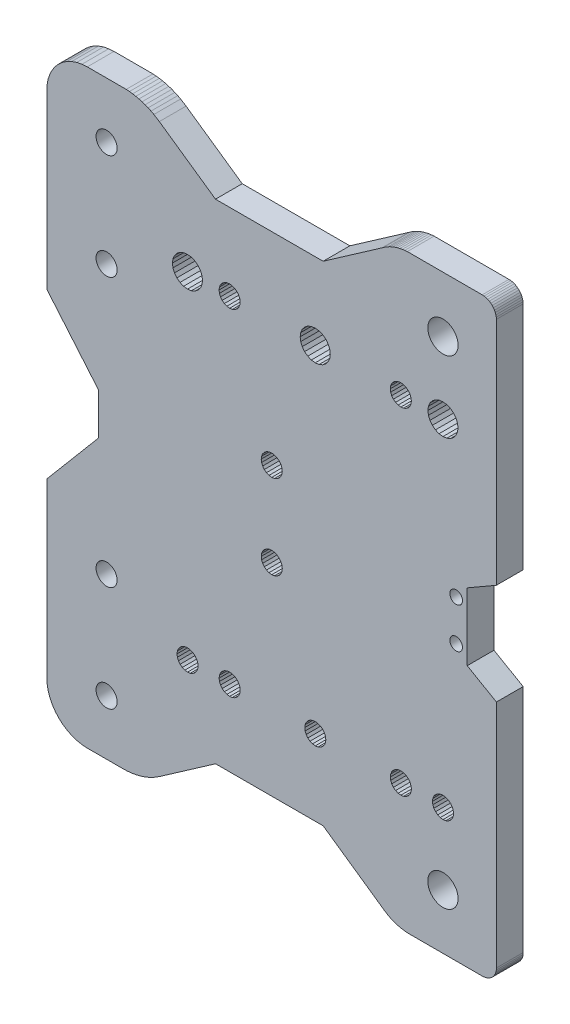
from build123d import *

# Parameters (mm, degrees)
MODEL_R             = 2.5
MODEL_R_2           = 1.5
MODEL_R_3           = 2.500000001
MODEL_R_4           = 3.6
BOSS_EXTRUDE1_DEPTH = 6.35


with BuildPart() as part:
    # Model → Boss-Extrude1 (new body)
    with BuildSketch(Plane.XY):
        Polygon((606.504363005, 163.455463636), (606.50782997, 147.455463886), (613.4360332, 143.455463886), (613.44392881, 88.798247656), (613.415223141, 88.359312218), (613.329470481, 87.927878776), (613.188138083, 87.511329275), (612.993644182, 87.116790992), (612.749316625, 86.751014587), (612.459335922, 86.420258596), (612.128663724, 86.130182345), (611.762957924, 85.88574912), (611.368475849, 85.69114124), (610.951967198, 85.549688501), (610.520558549, 85.463811197), (610.081631423, 85.434978715), (592.905761978, 85.439303293), (592.309445462, 85.455624065), (591.714939398, 85.504840872), (591.12405712, 85.586803594), (590.53860091, 85.701262234), (589.960356498, 85.847867673), (589.391087619, 86.026172744), (588.832530631, 86.235633588), (588.286389218, 86.475611319), (587.754329194, 86.745373966), (586.738896875, 87.370874402), (586.258621804, 87.72470432), (572.318335171, 97.436568259), (546.77102369, 97.424556188), (533.438032454, 88.130387183), (532.140915056, 87.320684471), (531.463244887, 86.966181731), (530.768474551, 86.646489331), (530.058390747, 86.362429405), (529.334819555, 86.114732453), (528.599621739, 85.904035462), (527.854687964, 85.730880268), (527.10193393, 85.595712166), (526.343295452, 85.498878757), (525.580723472, 85.440629064), (524.816179053, 85.421112883), (516.336465852, 85.419733916), (515.082354318, 85.501750787), (513.849677231, 85.746760396), (512.659526039, 86.15057056), (511.532264559, 86.706271975), (510.487180546, 87.404356436), (509.542155679, 88.232879525), (508.713359594, 89.177664981), (508.014973223, 90.222547264), (507.45894615, 91.349648147), (507.054792152, 92.539682623), (506.809426416, 93.772288872), (506.727047218, 95.026376658), (506.721133668, 135.962816223), (518.936441958, 150.441812844), (518.934997389, 160.44181274), (506.715502507, 174.944426011), (506.709593124, 215.852016485), (506.791609995, 217.10612802), (507.036619604, 218.338805107), (507.440429768, 219.528956299), (507.996131183, 220.656217779), (508.694215644, 221.701301792), (509.522738733, 222.646326659), (510.467524189, 223.475122744), (511.512406472, 224.173509115), (512.639507356, 224.729536188), (513.829541832, 225.133690186), (515.06214808, 225.379055922), (516.316235866, 225.46143512), (525.560496495, 225.461500347), (526.323085272, 225.403470973), (527.081751696, 225.30685675), (527.834544749, 225.171906134), (528.57952852, 224.99896617), (529.314787179, 224.788481596), (530.038429904, 224.540993704), (530.748595747, 224.257138942), (531.443458418, 223.937647284), (532.121230979, 223.583340347), (533.418582258, 222.774012425), (546.75425815, 213.483695891), (572.301569754, 213.494856629), (586.239049914, 223.210747703), (586.719222739, 223.564716363), (587.7344743, 224.190510146), (588.266456363, 224.460426501), (588.812528421, 224.700562009), (589.37102487, 224.91018422), (589.94024221, 225.088653753), (590.518444241, 225.235426249), (591.103867358, 225.35005403), (591.694725932, 225.432187463), (592.289217752, 225.481576028), (610.061401683, 225.474977253), (610.500337121, 225.446271584), (610.931770563, 225.360518924), (611.348320065, 225.219186525), (611.742858347, 225.024692625), (612.108634752, 224.780365067), (612.439390743, 224.490384364), (612.729466994, 224.159712166), (612.97390022, 223.794006366), (613.168508099, 223.399524292), (613.309960839, 222.983015641), (613.395838142, 222.551606992), (613.424670625, 222.112679866), (613.432566235, 167.455463636), align=None)
        with Locations((520.901831188, 187.242801268)):
            Circle(MODEL_R, mode=Mode.SUBTRACT)
        with Locations((603.881271716, 150.664358716)):
            Circle(MODEL_R_2, mode=Mode.SUBTRACT)
        with Locations((603.881271716, 160.244358616)):
            Circle(MODEL_R_2, mode=Mode.SUBTRACT)
        with Locations((520.902281683, 123.476551269)):
            Circle(MODEL_R_3, mode=Mode.SUBTRACT)
        with Locations((600.742457856, 98.47958)):
            Circle(MODEL_R_4, mode=Mode.SUBTRACT)
        with Locations((600.745309717, 212.245836)):
            Circle(MODEL_R_4, mode=Mode.SUBTRACT)
        with Locations((520.905302241, 212.245836805)):
            Circle(MODEL_R, mode=Mode.SUBTRACT)
        with Locations((520.906104967, 98.479586806)):
            Circle(MODEL_R, mode=Mode.SUBTRACT)
        Polygon((547.938669143, 193.99416413), (548.336040491, 193.476454574), (548.853864831, 193.079232817), (549.456853291, 192.829568864), (550.103913203, 192.744476901), (550.750948503, 192.829755805), (551.353864806, 193.079593959), (551.871574362, 193.476965306), (552.268796119, 193.994789647), (552.518460073, 194.597778106), (552.603552036, 195.244838018), (552.518273132, 195.891873319), (552.268434977, 196.494789622), (551.87106363, 197.012499177), (551.35323929, 197.409720935), (550.75025083, 197.659384888), (550.103190918, 197.744476851), (549.456155618, 197.659197947), (548.853239315, 197.409359793), (548.335529759, 197.011988445), (547.938308001, 196.494164105), (547.688644048, 195.891175646), (547.603552085, 195.244115734), (547.688830989, 194.597080433), align=None, mode=Mode.SUBTRACT)
        Polygon((557.945858514, 144.226600638), (558.343229862, 143.708891083), (558.861054202, 143.311669325), (559.464042661, 143.062005372), (560.111102573, 142.976913409), (560.758137874, 143.062192313), (561.361054177, 143.312030467), (561.878763733, 143.709401815), (562.27598549, 144.227226155), (562.525649443, 144.830214614), (562.610741406, 145.477274526), (562.525462502, 146.124309827), (562.275624348, 146.72722613), (561.878253, 147.244935686), (561.36042866, 147.642157443), (560.757440201, 147.891821397), (560.110380289, 147.976913359), (559.463344988, 147.891634455), (558.860428685, 147.641796301), (558.34271913, 147.244424954), (557.945497372, 146.726600614), (557.695833419, 146.123612154), (557.610741456, 145.476552242), (557.69602036, 144.829516941), align=None, mode=Mode.SUBTRACT)
        Polygon((598.59019624, 114.20099651), (598.987567588, 113.683286955), (599.505391927, 113.286065197), (600.108380387, 113.036401244), (600.755440299, 112.951309281), (601.4024756, 113.036588185), (602.005391903, 113.286426339), (602.523101458, 113.683797687), (602.920323216, 114.201622027), (603.169987169, 114.804610486), (603.255079132, 115.451670398), (603.169800228, 116.098705699), (602.919962074, 116.701622002), (602.522590726, 117.219331557), (602.004766386, 117.616553315), (601.401777927, 117.866217268), (600.754718015, 117.951309231), (600.107682714, 117.866030327), (599.504766411, 117.616192173), (598.987056855, 117.218820825), (598.589835098, 116.700996485), (598.340171145, 116.098008026), (598.255079182, 115.450948114), (598.340358086, 114.803912813), align=None, mode=Mode.SUBTRACT)
        Polygon((597.65288206, 197.035595722), (597.296511733, 196.174889995), (597.175051466, 195.251276677), (597.296778573, 194.327698489), (597.653397554, 193.467095759), (598.220605416, 192.728117139), (598.959747878, 192.161122803), (599.820453605, 191.804752476), (600.744066923, 191.683292208), (601.667645111, 191.805019316), (602.528247842, 192.161638297), (603.267226461, 192.728846159), (603.834220798, 193.467988621), (604.190591124, 194.328694348), (604.312051392, 195.252307666), (604.190324285, 196.175885854), (603.833705303, 197.036488584), (603.266497442, 197.775467204), (602.527354979, 198.34246154), (601.666649252, 198.698831867), (600.743035934, 198.820292135), (599.819457747, 198.698565027), (598.958855016, 198.341946046), (598.219876397, 197.774738185), align=None, mode=Mode.SUBTRACT)
        Polygon((537.950196976, 114.192236646), (538.347568323, 113.67452709), (538.865392663, 113.277305333), (539.468381123, 113.027641379), (540.115441035, 112.942549416), (540.762476336, 113.02782832), (541.365392639, 113.277666475), (541.883102194, 113.675037822), (542.280323952, 114.192862162), (542.529987905, 114.795850622), (542.615079868, 115.442910534), (542.529800964, 116.089945834), (542.27996281, 116.692862137), (541.882591462, 117.210571693), (541.364767122, 117.607793451), (540.761778662, 117.857457404), (540.11471875, 117.942549367), (539.46768345, 117.857270463), (538.864767147, 117.607432308), (538.347057591, 117.210060961), (537.949835834, 116.692236621), (537.70017188, 116.089248161), (537.615079917, 115.442188249), (537.700358821, 114.795152949), align=None, mode=Mode.SUBTRACT)
        Polygon((547.95019499, 114.206702671), (548.347566338, 113.688993115), (548.865390678, 113.291771357), (549.468379138, 113.042107404), (550.115439049, 112.957015441), (550.76247435, 113.042294345), (551.365390653, 113.2921325), (551.883100209, 113.689503847), (552.280321966, 114.207328187), (552.529985919, 114.810316647), (552.615077883, 115.457376559), (552.529798979, 116.104411859), (552.279960824, 116.707328162), (551.882589477, 117.225037718), (551.364765137, 117.622259476), (550.761776677, 117.871923429), (550.114716765, 117.957015392), (549.467681464, 117.871736488), (548.864765161, 117.621898333), (548.347055606, 117.224526986), (547.949833848, 116.706702646), (547.700169895, 116.103714186), (547.615077932, 115.456654274), (547.700356836, 114.809618974), align=None, mode=Mode.SUBTRACT)
        Polygon((567.337421335, 197.031216445), (566.981051009, 196.170510719), (566.859590741, 195.246897401), (566.981317848, 194.323319213), (567.337936829, 193.462716482), (567.905144691, 192.723737863), (568.644287154, 192.156743526), (569.50499288, 191.8003732), (570.428606198, 191.678912932), (571.352184386, 191.800640039), (572.212787117, 192.157259021), (572.951765736, 192.724466882), (573.518760073, 193.463609345), (573.875130399, 194.324315071), (573.996590667, 195.247928389), (573.87486356, 196.171506577), (573.518244578, 197.032109308), (572.951036717, 197.771087927), (572.211894254, 198.338082264), (571.351188527, 198.69445259), (570.427575209, 198.815912858), (569.503997022, 198.694185751), (568.643394291, 198.337566769), (567.904415672, 197.770358908), align=None, mode=Mode.SUBTRACT)
        Polygon((568.274735515, 114.196617234), (568.672106862, 113.678907678), (569.189931203, 113.28168592), (569.792919662, 113.032021967), (570.439979574, 112.946930004), (571.087014875, 113.032208908), (571.689931178, 113.282047063), (572.207640733, 113.67941841), (572.604862491, 114.19724275), (572.854526444, 114.80023121), (572.939618407, 115.447291122), (572.854339503, 116.094326422), (572.604501349, 116.697242725), (572.207130001, 117.214952281), (571.689305661, 117.612174039), (571.086317202, 117.861837992), (570.43925729, 117.946929955), (569.792221989, 117.861651051), (569.189305686, 117.611812896), (568.67159613, 117.214441549), (568.274374373, 116.696617209), (568.02471042, 116.093628749), (567.939618457, 115.446568837), (568.024897361, 114.799533537), align=None, mode=Mode.SUBTRACT)
        Polygon((588.590194463, 114.212573398), (588.987565811, 113.694863842), (589.505390151, 113.297642085), (590.10837861, 113.047978131), (590.755438522, 112.962886169), (591.402473823, 113.048165072), (592.005390126, 113.298003227), (592.523099682, 113.695374574), (592.920321439, 114.213198914), (593.169985392, 114.816187374), (593.255077355, 115.463247286), (593.169798451, 116.110282587), (592.919960297, 116.71319889), (592.522588949, 117.230908445), (592.004764609, 117.628130203), (591.40177615, 117.877794156), (590.754716238, 117.962886119), (590.107680937, 117.877607215), (589.504764634, 117.627769061), (588.987055079, 117.230397713), (588.589833321, 116.712573373), (588.340169368, 116.109584913), (588.255077405, 115.462525002), (588.340356309, 114.815489701), align=None, mode=Mode.SUBTRACT)
        Polygon((588.578668616, 194.000034857), (588.976039964, 193.482325301), (589.493864304, 193.085103544), (590.096852763, 192.835439591), (590.743912675, 192.750347628), (591.390947976, 192.835626532), (591.993864279, 193.085464686), (592.511573835, 193.482836034), (592.908795592, 194.000660374), (593.158459545, 194.603648833), (593.243551508, 195.250708745), (593.158272604, 195.897744046), (592.90843445, 196.500660349), (592.511063102, 197.018369904), (591.993238762, 197.415591662), (591.390250303, 197.665255615), (590.743190391, 197.750347578), (590.09615509, 197.665068674), (589.493238787, 197.41523052), (588.975529232, 197.017859172), (588.578307474, 196.500034832), (588.328643521, 195.897046373), (588.243551558, 195.249986461), (588.328830462, 194.60295116), align=None, mode=Mode.SUBTRACT)
        Polygon((557.942969377, 164.22660043), (558.340340724, 163.708890874), (558.858165064, 163.311669117), (559.461153524, 163.062005163), (560.108213436, 162.9769132), (560.755248737, 163.062192104), (561.35816504, 163.312030259), (561.875874595, 163.709401606), (562.273096353, 164.227225946), (562.522760306, 164.830214406), (562.607852269, 165.477274318), (562.522573365, 166.124309618), (562.272735211, 166.727225921), (561.875363863, 167.244935477), (561.357539523, 167.642157235), (560.754551064, 167.891821188), (560.107491152, 167.976913151), (559.460455851, 167.891634247), (558.857539548, 167.641796092), (558.339829992, 167.244424745), (557.942608235, 166.726600405), (557.692944281, 166.123611945), (557.607852319, 165.476552033), (557.693131223, 164.829516733), align=None, mode=Mode.SUBTRACT)
        Polygon((537.012882796, 197.026835858), (536.656512469, 196.166130131), (536.535052201, 195.242516813), (536.656779309, 194.318938625), (537.01339829, 193.458335894), (537.580606152, 192.719357275), (538.319748614, 192.152362938), (539.180454341, 191.795992612), (540.104067659, 191.674532344), (541.027645847, 191.796259451), (541.888248578, 192.152878433), (542.627227197, 192.720086294), (543.194221533, 193.459228757), (543.55059186, 194.319934483), (543.672052128, 195.243547801), (543.550325021, 196.167125989), (543.193706039, 197.02772872), (542.626498178, 197.766707339), (541.887355715, 198.333701676), (541.026649988, 198.690072002), (540.10303667, 198.81153227), (539.179458482, 198.689805163), (538.318855752, 198.333186181), (537.579877132, 197.76597832), align=None, mode=Mode.SUBTRACT)
    extrude(amount=BOSS_EXTRUDE1_DEPTH)


solid = part.part
